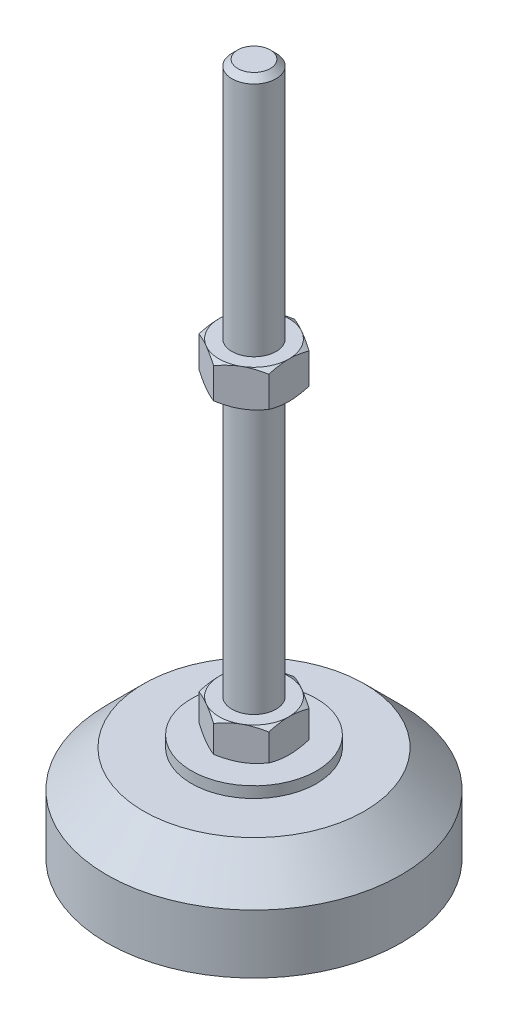
from build123d import *

# Parameters (mm, degrees)
EXTRUDE_1_DEPTH = 9
EXTRUDE_2_DEPTH = 10


with BuildPart() as part:
    # Эскиз1 → Повернуть1 (revolve)
    with BuildSketch(Plane.XY, mode=Mode.PRIVATE) as revolve_1_sk:
        Polygon((0, 0), (-40, 0), (-40, 16), (-30, 26), (-17, 26), (-17, 29), (-6, 29), (-6, 38), (-6, 186.4), (-4.4, 188), (0, 188), align=None)
    revolve(revolve_1_sk.sketch.rotate(Axis((0, 0, 0), (0, 1, 0)), 180), axis=Axis((0, 0, 0), (0, 1, 0)))  # turned: the seam where the file's is

    # Эскиз2 → Бобышка-Вытянуть1 (add)
    with BuildSketch(Plane(origin=(0, 29, 0), x_dir=(1, 0, 0), z_dir=(0, 1, 0))):
        Polygon((0, 10.969655115), (-9.5, 5.484827557), (-9.5, -5.484827557), (0, -10.969655115), (9.5, -5.484827557), (9.5, 5.484827557), align=None)
    extrude(amount=EXTRUDE_1_DEPTH)

    # Эскиз3 → Бобышка-Вытянуть2 (add)
    with BuildSketch(Plane(origin=(0, 112.2, 0), x_dir=(1, 0, 0), z_dir=(0, 1, 0))):
        Polygon((9.5, 5.484827557), (0, 10.969655115), (-9.5, 5.484827557), (-9.5, -5.484827557), (0, -10.969655115), (9.5, -5.484827557), align=None)
    extrude(amount=EXTRUDE_2_DEPTH)

    # Эскиз4 → Вырез-Повернуть2 (revolve, cut)
    with BuildSketch(Plane.XY, mode=Mode.PRIVATE) as cut_revolve_2_sk:
        Polygon((-18.160254038, 122.2), (-9.5, 122.2), (-18.160254038, 117.2), align=None)
        Polygon((-18.160254038, 112.2), (-18.160254038, 117.2), (-9.5, 112.2), align=None)
        Polygon((-17.294228634, 38), (-17.294228634, 33.5), (-9.5, 38), align=None)
        Polygon((-17.294228634, 33.5), (-17.294228634, 29), (-9.5, 29), align=None)
    revolve(cut_revolve_2_sk.sketch.rotate(Axis((0, 188, 0), (0, -1, 0)), 180), axis=Axis((0, 188, 0), (0, -1, 0)), mode=Mode.SUBTRACT)  # turned: the seam where the file's is


solid = part.part
